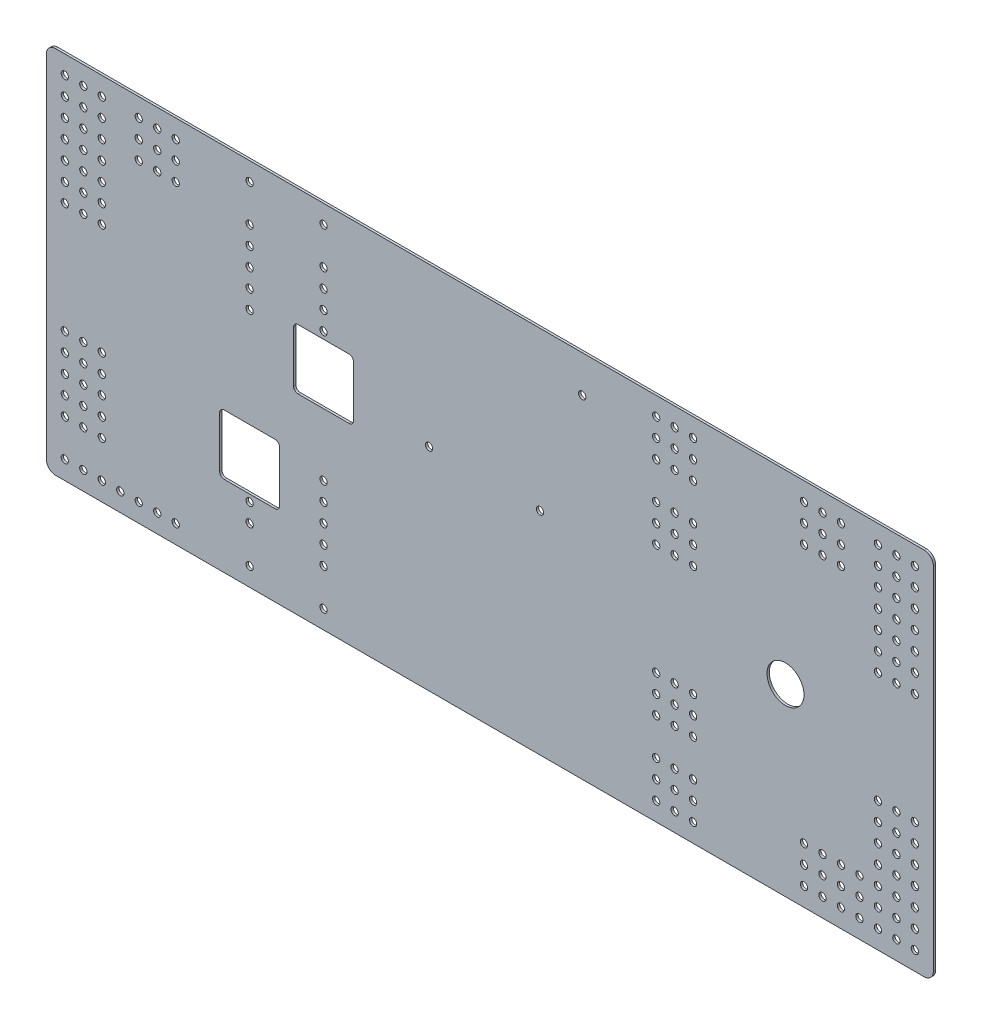
from build123d import *

# Parameters (mm, degrees)
SKETCH1_R           = 12.7
BOSS_EXTRUDE1_DEPTH = 1.5875
SKETCH2_R           = 2.5
CUT_EXTRUDE1_DEPTH  = 2.5875
CUT_EXTRUDE2_DEPTH  = 2.5875
SKETCH5_R           = 2.5
CUT_EXTRUDE3_DEPTH  = 2.5875
SKETCH7_R           = 2.5
CUT_EXTRUDE4_DEPTH  = 2.5875


with BuildPart() as part:
    # Sketch1 → Boss-Extrude1 (new body)
    with BuildSketch(Plane.XY):
        with BuildLine():
            Line((-148.965673289, 122.233995585), (447.934326711, 122.233995585))
            ThreePointArc((447.934326711, 122.233995585), (452.424454771, 120.374123646), (454.284326711, 115.883995585))
            Line((454.284326711, 115.883995585), (454.284326711, -125.416004415))
            ThreePointArc((454.284326711, -125.416004415), (452.424454771, -129.906132476), (447.934326711, -131.766004415))
            Line((447.934326711, -131.766004415), (-148.965673289, -131.766004415))
            ThreePointArc((-148.965673289, -131.766004415), (-153.45580135, -129.906132476), (-155.315673289, -125.416004415))
            Line((-155.315673289, -125.416004415), (-155.315673289, 115.883995585))
            ThreePointArc((-155.315673289, 115.883995585), (-153.45580135, 120.374123646), (-148.965673289, 122.233995585))
        make_face()
        with Locations((352.684326711, -5.226755188)):
            Circle(SKETCH1_R, mode=Mode.SUBTRACT)
    extrude(amount=BOSS_EXTRUDE1_DEPTH)

    # Sketch2 → Cut-Extrude1 (cut, through all)
    with BuildSketch(Plane.XY.offset(1.5875)):
        with Locations((-142.615673289, 109.533995585)):
            Circle(SKETCH2_R)
        with Locations((-129.915673289, 109.533995585)):
            Circle(SKETCH2_R)
        with Locations((-117.215673289, 109.533995585)):
            Circle(SKETCH2_R)
        with Locations((-91.815673289, 109.533995585)):
            Circle(SKETCH2_R)
        with Locations((-79.115673289, 109.533995585)):
            Circle(SKETCH2_R)
        with Locations((-66.415673289, 109.533995585)):
            Circle(SKETCH2_R)
        with Locations((-129.915673289, 96.833995585)):
            Circle(SKETCH2_R)
        with Locations((-117.215673289, 96.833995585)):
            Circle(SKETCH2_R)
        with Locations((-91.815673289, 96.833995585)):
            Circle(SKETCH2_R)
        with Locations((-79.115673289, 96.833995585)):
            Circle(SKETCH2_R)
        with Locations((-66.415673289, 96.833995585)):
            Circle(SKETCH2_R)
        with Locations((-129.915673289, 84.133995585)):
            Circle(SKETCH2_R)
        with Locations((-117.215673289, 84.133995585)):
            Circle(SKETCH2_R)
        with Locations((-91.815673289, 84.133995585)):
            Circle(SKETCH2_R)
        with Locations((-79.115673289, 84.133995585)):
            Circle(SKETCH2_R)
        with Locations((-66.415673289, 84.133995585)):
            Circle(SKETCH2_R)
        with Locations((-142.615673289, 96.833995585)):
            Circle(SKETCH2_R)
        with Locations((-142.615673289, 84.133995585)):
            Circle(SKETCH2_R)
        with Locations((-142.615673289, 71.433995585)):
            Circle(SKETCH2_R)
        with Locations((-129.915673289, 71.433995585)):
            Circle(SKETCH2_R)
        with Locations((-117.215673289, 71.433995585)):
            Circle(SKETCH2_R)
        with Locations((-129.915673289, 58.733995585)):
            Circle(SKETCH2_R)
        with Locations((-117.215673289, 58.733995585)):
            Circle(SKETCH2_R)
        with Locations((-129.915673289, 46.033995585)):
            Circle(SKETCH2_R)
        with Locations((-117.215673289, 46.033995585)):
            Circle(SKETCH2_R)
        with Locations((-129.915673289, 33.333995585)):
            Circle(SKETCH2_R)
        with Locations((-117.215673289, 33.333995585)):
            Circle(SKETCH2_R)
        with Locations((-142.615673289, 58.733995585)):
            Circle(SKETCH2_R)
        with Locations((-142.615673289, 46.033995585)):
            Circle(SKETCH2_R)
        with Locations((-142.615673289, 33.333995585)):
            Circle(SKETCH2_R)
        with Locations((-142.615673289, -42.866004415)):
            Circle(SKETCH2_R)
        with Locations((-142.615673289, -55.566004415)):
            Circle(SKETCH2_R)
        with Locations((-142.615673289, -68.266004415)):
            Circle(SKETCH2_R)
        with Locations((-117.215673289, -42.866004415)):
            Circle(SKETCH2_R)
        with Locations((-129.915673289, -42.866004415)):
            Circle(SKETCH2_R)
        with Locations((-117.215673289, -55.566004415)):
            Circle(SKETCH2_R)
        with Locations((-129.915673289, -55.566004415)):
            Circle(SKETCH2_R)
        with Locations((-117.215673289, -68.266004415)):
            Circle(SKETCH2_R)
        with Locations((-129.915673289, -68.266004415)):
            Circle(SKETCH2_R)
        with Locations((-117.215673289, -80.966004415)):
            Circle(SKETCH2_R)
        with Locations((-129.915673289, -80.966004415)):
            Circle(SKETCH2_R)
        with Locations((-142.615673289, -80.966004415)):
            Circle(SKETCH2_R)
        with Locations((-142.615673289, -93.666004415)):
            Circle(SKETCH2_R)
        with Locations((-117.215673289, -93.666004415)):
            Circle(SKETCH2_R)
        with Locations((-129.915673289, -93.666004415)):
            Circle(SKETCH2_R)
        with Locations((-66.415673289, -119.066004415)):
            Circle(SKETCH2_R)
        with Locations((-79.115673289, -119.066004415)):
            Circle(SKETCH2_R)
        with Locations((-91.815673289, -119.066004415)):
            Circle(SKETCH2_R)
        with Locations((-104.515673289, -119.066004415)):
            Circle(SKETCH2_R)
        with Locations((-117.215673289, -119.066004415)):
            Circle(SKETCH2_R)
        with Locations((-129.915673289, -119.066004415)):
            Circle(SKETCH2_R)
        with Locations((-142.615673289, -119.066004415)):
            Circle(SKETCH2_R)
        with Locations((441.584326711, -119.066004415)):
            Circle(SKETCH2_R)
        with Locations((428.884326711, -119.066004415)):
            Circle(SKETCH2_R)
        with Locations((416.184326711, -119.066004415)):
            Circle(SKETCH2_R)
        with Locations((403.484326711, -119.066004415)):
            Circle(SKETCH2_R)
        with Locations((390.784326711, -119.066004415)):
            Circle(SKETCH2_R)
        with Locations((378.084326711, -119.066004415)):
            Circle(SKETCH2_R)
        with Locations((365.384326711, -119.066004415)):
            Circle(SKETCH2_R)
        with Locations((428.884326711, -106.366004415)):
            Circle(SKETCH2_R)
        with Locations((416.184326711, -106.366004415)):
            Circle(SKETCH2_R)
        with Locations((403.484326711, -106.366004415)):
            Circle(SKETCH2_R)
        with Locations((390.784326711, -106.366004415)):
            Circle(SKETCH2_R)
        with Locations((378.084326711, -106.366004415)):
            Circle(SKETCH2_R)
        with Locations((365.384326711, -106.366004415)):
            Circle(SKETCH2_R)
        with Locations((428.884326711, -93.666004415)):
            Circle(SKETCH2_R)
        with Locations((416.184326711, -93.666004415)):
            Circle(SKETCH2_R)
        with Locations((403.484326711, -93.666004415)):
            Circle(SKETCH2_R)
        with Locations((390.784326711, -93.666004415)):
            Circle(SKETCH2_R)
        with Locations((378.084326711, -93.666004415)):
            Circle(SKETCH2_R)
        with Locations((365.384326711, -93.666004415)):
            Circle(SKETCH2_R)
        with Locations((441.584326711, -106.366004415)):
            Circle(SKETCH2_R)
        with Locations((441.584326711, -93.666004415)):
            Circle(SKETCH2_R)
        with Locations((441.584326711, -80.966004415)):
            Circle(SKETCH2_R)
        with Locations((428.884326711, -80.966004415)):
            Circle(SKETCH2_R)
        with Locations((416.184326711, -80.966004415)):
            Circle(SKETCH2_R)
        with Locations((428.884326711, -68.266004415)):
            Circle(SKETCH2_R)
        with Locations((416.184326711, -68.266004415)):
            Circle(SKETCH2_R)
        with Locations((428.884326711, -55.566004415)):
            Circle(SKETCH2_R)
        with Locations((416.184326711, -55.566004415)):
            Circle(SKETCH2_R)
        with Locations((428.884326711, -42.866004415)):
            Circle(SKETCH2_R)
        with Locations((416.184326711, -42.866004415)):
            Circle(SKETCH2_R)
        with Locations((441.584326711, -68.266004415)):
            Circle(SKETCH2_R)
        with Locations((441.584326711, -55.566004415)):
            Circle(SKETCH2_R)
        with Locations((441.584326711, -42.866004415)):
            Circle(SKETCH2_R)
        with Locations((441.584326711, 33.333995585)):
            Circle(SKETCH2_R)
        with Locations((441.584326711, 46.033995585)):
            Circle(SKETCH2_R)
        with Locations((441.584326711, 58.733995585)):
            Circle(SKETCH2_R)
        with Locations((416.184326711, 33.333995585)):
            Circle(SKETCH2_R)
        with Locations((416.184326711, 46.033995585)):
            Circle(SKETCH2_R)
        with Locations((416.184326711, 58.733995585)):
            Circle(SKETCH2_R)
        with Locations((416.184326711, 71.433995585)):
            Circle(SKETCH2_R)
        with Locations((441.584326711, 71.433995585)):
            Circle(SKETCH2_R)
        with Locations((441.584326711, 84.133995585)):
            Circle(SKETCH2_R)
        with Locations((441.584326711, 96.833995585)):
            Circle(SKETCH2_R)
        with Locations((365.384326711, 84.133995585)):
            Circle(SKETCH2_R)
        with Locations((378.084326711, 84.133995585)):
            Circle(SKETCH2_R)
        with Locations((390.784326711, 84.133995585)):
            Circle(SKETCH2_R)
        with Locations((416.184326711, 84.133995585)):
            Circle(SKETCH2_R)
        with Locations((428.884326711, 84.133995585)):
            Circle(SKETCH2_R)
        with Locations((365.384326711, 96.833995585)):
            Circle(SKETCH2_R)
        with Locations((378.084326711, 96.833995585)):
            Circle(SKETCH2_R)
        with Locations((390.784326711, 96.833995585)):
            Circle(SKETCH2_R)
        with Locations((416.184326711, 96.833995585)):
            Circle(SKETCH2_R)
        with Locations((428.884326711, 96.833995585)):
            Circle(SKETCH2_R)
        with Locations((365.384326711, 109.533995585)):
            Circle(SKETCH2_R)
        with Locations((378.084326711, 109.533995585)):
            Circle(SKETCH2_R)
        with Locations((390.784326711, 109.533995585)):
            Circle(SKETCH2_R)
        with Locations((416.184326711, 109.533995585)):
            Circle(SKETCH2_R)
        with Locations((428.884326711, 109.533995585)):
            Circle(SKETCH2_R)
        with Locations((441.584326711, 109.533995585)):
            Circle(SKETCH2_R)
        with Locations((-15.615673289, 109.533995585)):
            Circle(SKETCH2_R)
        with Locations((35.184326711, 109.533995585)):
            Circle(SKETCH2_R)
        with Locations((-15.615673289, 84.133995585)):
            Circle(SKETCH2_R)
        with Locations((35.184326711, 84.133995585)):
            Circle(SKETCH2_R)
        with Locations((-15.615673289, 71.433995585)):
            Circle(SKETCH2_R)
        with Locations((35.184326711, 71.433995585)):
            Circle(SKETCH2_R)
        with Locations((-15.615673289, 58.733995585)):
            Circle(SKETCH2_R)
        with Locations((35.184326711, 58.733995585)):
            Circle(SKETCH2_R)
        with Locations((-15.615673289, 46.033995585)):
            Circle(SKETCH2_R)
        with Locations((35.184326711, 46.033995585)):
            Circle(SKETCH2_R)
        with Locations((-15.615673289, 33.333995585)):
            Circle(SKETCH2_R)
        with Locations((35.184326711, 33.333995585)):
            Circle(SKETCH2_R)
        with Locations((35.184326711, -42.866004415)):
            Circle(SKETCH2_R)
        with Locations((-15.615673289, -42.866004415)):
            Circle(SKETCH2_R)
        with Locations((35.184326711, -55.566004415)):
            Circle(SKETCH2_R)
        with Locations((-15.615673289, -55.566004415)):
            Circle(SKETCH2_R)
        with Locations((35.184326711, -68.266004415)):
            Circle(SKETCH2_R)
        with Locations((-15.615673289, -68.266004415)):
            Circle(SKETCH2_R)
        with Locations((35.184326711, -80.966004415)):
            Circle(SKETCH2_R)
        with Locations((-15.615673289, -80.966004415)):
            Circle(SKETCH2_R)
        with Locations((35.184326711, -93.666004415)):
            Circle(SKETCH2_R)
        with Locations((-15.615673289, -93.666004415)):
            Circle(SKETCH2_R)
        with Locations((35.184326711, -119.066004415)):
            Circle(SKETCH2_R)
        with Locations((-15.615673289, -119.066004415)):
            Circle(SKETCH2_R)
        with Locations((289.184326711, 109.533995585)):
            Circle(SKETCH2_R)
        with Locations((276.484326711, 109.533995585)):
            Circle(SKETCH2_R)
        with Locations((263.784326711, 109.533995585)):
            Circle(SKETCH2_R)
        with Locations((276.484326711, 96.833995585)):
            Circle(SKETCH2_R)
        with Locations((263.784326711, 96.833995585)):
            Circle(SKETCH2_R)
        with Locations((276.484326711, 84.133995585)):
            Circle(SKETCH2_R)
        with Locations((263.784326711, 84.133995585)):
            Circle(SKETCH2_R)
        with Locations((276.484326711, 58.733995585)):
            Circle(SKETCH2_R)
        with Locations((263.784326711, 58.733995585)):
            Circle(SKETCH2_R)
        with Locations((276.484326711, 46.033995585)):
            Circle(SKETCH2_R)
        with Locations((263.784326711, 46.033995585)):
            Circle(SKETCH2_R)
        with Locations((276.484326711, 33.333995585)):
            Circle(SKETCH2_R)
        with Locations((263.784326711, 33.333995585)):
            Circle(SKETCH2_R)
        with Locations((289.184326711, 96.833995585)):
            Circle(SKETCH2_R)
        with Locations((289.184326711, 84.133995585)):
            Circle(SKETCH2_R)
        with Locations((289.184326711, 58.733995585)):
            Circle(SKETCH2_R)
        with Locations((289.184326711, 46.033995585)):
            Circle(SKETCH2_R)
        with Locations((289.184326711, 33.333995585)):
            Circle(SKETCH2_R)
        with Locations((289.184326711, -42.866004415)):
            Circle(SKETCH2_R)
        with Locations((289.184326711, -55.566004415)):
            Circle(SKETCH2_R)
        with Locations((289.184326711, -68.266004415)):
            Circle(SKETCH2_R)
        with Locations((289.184326711, -106.366004415)):
            Circle(SKETCH2_R)
        with Locations((263.784326711, -42.866004415)):
            Circle(SKETCH2_R)
        with Locations((276.484326711, -42.866004415)):
            Circle(SKETCH2_R)
        with Locations((263.784326711, -55.566004415)):
            Circle(SKETCH2_R)
        with Locations((276.484326711, -55.566004415)):
            Circle(SKETCH2_R)
        with Locations((263.784326711, -68.266004415)):
            Circle(SKETCH2_R)
        with Locations((276.484326711, -68.266004415)):
            Circle(SKETCH2_R)
        with Locations((263.784326711, -106.366004415)):
            Circle(SKETCH2_R)
        with Locations((276.484326711, -106.366004415)):
            Circle(SKETCH2_R)
        with Locations((263.784326711, -119.066004415)):
            Circle(SKETCH2_R)
        with Locations((276.484326711, -119.066004415)):
            Circle(SKETCH2_R)
        with Locations((289.184326711, -119.066004415)):
            Circle(SKETCH2_R)
        with Locations((428.884326711, 71.433995585)):
            Circle(SKETCH2_R)
        with Locations((428.884326711, 58.733995585)):
            Circle(SKETCH2_R)
        with Locations((428.884326711, 46.033995585)):
            Circle(SKETCH2_R)
        with Locations((428.884326711, 33.333995585)):
            Circle(SKETCH2_R)
        with Locations((289.184326711, -93.666004415)):
            Circle(SKETCH2_R)
        with Locations((276.484326711, -93.666004415)):
            Circle(SKETCH2_R)
        with Locations((263.784326711, -93.666004415)):
            Circle(SKETCH2_R)
    extrude(amount=-CUT_EXTRUDE1_DEPTH, mode=Mode.SUBTRACT)

    # Sketch3 → Cut-Extrude2 (cut, through all)
    with BuildSketch(Plane(origin=(0, 0, 0), x_dir=(-1, 0, 0), z_dir=(0, 0, -1))):
        with BuildLine():
            Line((-1.846826711, -34.928504415), (33.078173289, -34.928504415))
            ThreePointArc((33.078173289, -34.928504415), (35.323237319, -35.858440385), (36.253173289, -38.103504415))
            Line((36.253173289, -38.103504415), (36.253173289, -73.028504415))
            ThreePointArc((36.253173289, -73.028504415), (35.323237319, -75.273568445), (33.078173289, -76.203504415))
            Line((33.078173289, -76.203504415), (-1.846826711, -76.203504415))
            ThreePointArc((-1.846826711, -76.203504415), (-4.091890741, -75.273568445), (-5.021826711, -73.028504415))
            Line((-5.021826711, -73.028504415), (-5.021826711, -38.103504415))
            ThreePointArc((-5.021826711, -38.103504415), (-4.091890741, -35.858440385), (-1.846826711, -34.928504415))
        make_face()
        with BuildLine():
            Line((-52.646826711, 41.271495585), (-17.721826711, 41.271495585))
            ThreePointArc((-17.721826711, 41.271495585), (-15.476762681, 40.341559615), (-14.546826711, 38.096495585))
            Line((-14.546826711, 38.096495585), (-14.546826711, 3.171495585))
            ThreePointArc((-14.546826711, 3.171495585), (-15.476762681, 0.926431555), (-17.721826711, -0.003504415))
            Line((-17.721826711, -0.003504415), (-52.646826711, -0.003504415))
            ThreePointArc((-52.646826711, -0.003504415), (-54.891890741, 0.926431555), (-55.821826711, 3.171495585))
            Line((-55.821826711, 3.171495585), (-55.821826711, 38.096495585))
            ThreePointArc((-55.821826711, 38.096495585), (-54.891890741, 40.341559615), (-52.646826711, 41.271495585))
        make_face()
    extrude(amount=-CUT_EXTRUDE2_DEPTH, mode=Mode.SUBTRACT)

    # Sketch5 → Cut-Extrude3 (cut, through all)
    with BuildSketch(Plane.XY.offset(1.5875)):
        with Locations((212.984326711, 96.833995585)):
            Circle(SKETCH5_R)
    extrude(amount=-CUT_EXTRUDE3_DEPTH, mode=Mode.SUBTRACT)

    # Sketch7 → Cut-Extrude4 (cut, through all)
    with BuildSketch(Plane.XY.offset(1.5875)):
        with Locations((183.894619699, 13.620107589)):
            Circle(SKETCH7_R)
        with Locations((107.694619699, 13.620107589)):
            Circle(SKETCH7_R)
    extrude(amount=-CUT_EXTRUDE4_DEPTH, mode=Mode.SUBTRACT)


solid = part.part
